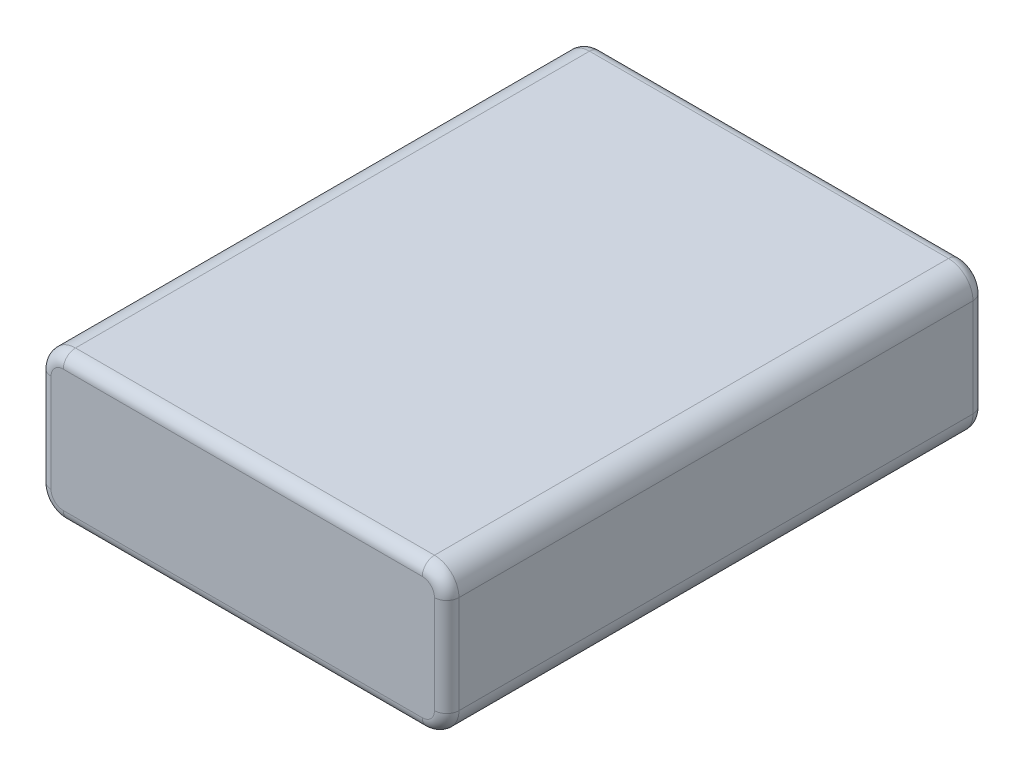
from build123d import *

# Parameters (mm, degrees)
BOSS_EXTRUDE1_DEPTH = 18
FILLET1_R           = 3
FILLET2_R           = 1.5


with BuildPart() as part:
    # Sketch1 → Boss-Extrude1 (new body)
    with BuildSketch(Plane(origin=(0, 0, 0), x_dir=(1, 0, 0), z_dir=(0, 1, 0))):
        Polygon((25, 0), (25, 33), (-25, 33), (-25, -33), (25, -33), align=None)
    extrude(amount=BOSS_EXTRUDE1_DEPTH)

    # Fillet1
    fillet1_edges = [part.edges().sort_by_distance(p)[0] for p in [
        (-25, 18, 0),
        (25, 18, 0),
        (-25, 0, 0),
        (25, 0, 0),
    ]]
    fillet(fillet1_edges, radius=FILLET1_R)

    # Fillet2
    fillet2_edges = [part.edges().sort_by_distance(p)[0] for p in [
        (0, 18, -33),
        (0, 18, 33),
        (0, 0, -33),
        (-25, 9, -33),
        (25, 9, -33),
        (24.121320344, 0.878679656, -33),
        (-24.121320344, 0.878679656, -33),
        (-24.121320344, 17.121320344, -33),
        (24.121320344, 17.121320344, -33),
        (25, 9, 33),
        (0, 0, 33),
        (-25, 9, 33),
        (24.121320344, 0.878679656, 33),
        (-24.121320344, 0.878679656, 33),
        (-24.121320344, 17.121320344, 33),
        (24.121320344, 17.121320344, 33),
    ]]
    fillet(fillet2_edges, radius=FILLET2_R)


solid = part.part
